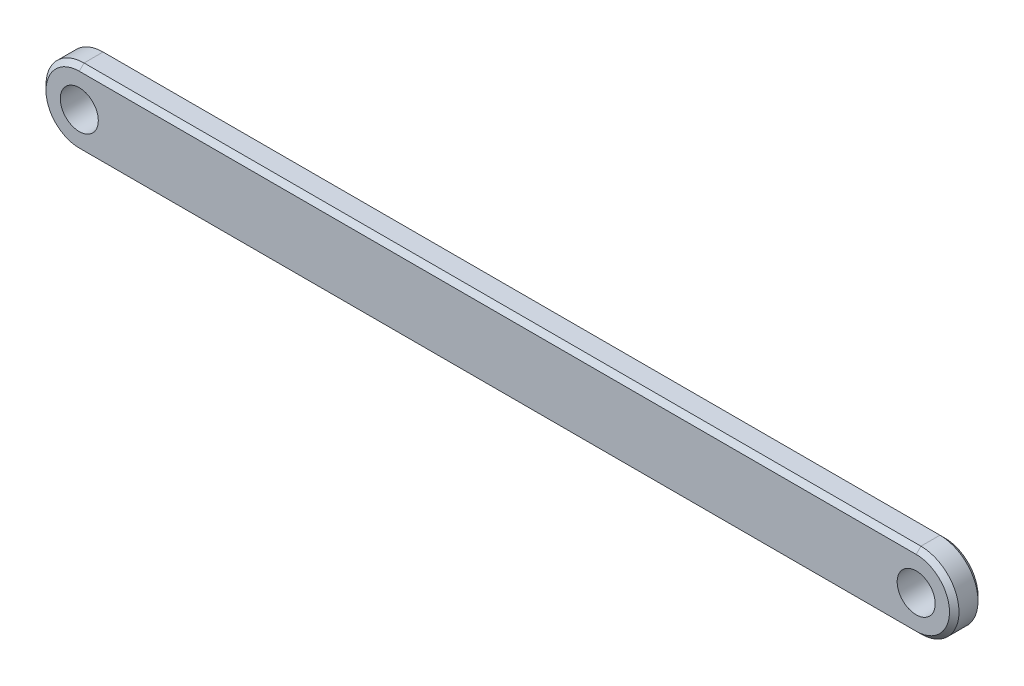
from build123d import *

# Parameters (mm, degrees)
SKETCH1_R           = 2
BOSS_EXTRUDE1_DEPTH = 3
CHAMFER1_SIZE       = 0.5


with BuildPart() as part:
    # Sketch1 → Boss-Extrude1 (new body)
    with BuildSketch(Plane.XY):
        with BuildLine():
            Line((-44, 4), (44, 4))
            ThreePointArc((44, 4), (48, 0), (44, -4))
            Line((44, -4), (-44, -4))
            ThreePointArc((-44, -4), (-48, 0), (-44, 4))
        make_face()
        with Locations((-44, 0)):
            Circle(SKETCH1_R, mode=Mode.SUBTRACT)
        with Locations((44, 0)):
            Circle(SKETCH1_R, mode=Mode.SUBTRACT)
    extrude(amount=BOSS_EXTRUDE1_DEPTH)

    # Chamfer1
    chamfer1_edges = [part.edges().sort_by_distance(p)[0] for p in [
        (48, 0, 3),
        (0, 4, 3),
        (-48, 0, 3),
        (0, 4, 0),
        (48, 0, 0),
        (0, -4, 0),
        (-48, 0, 0),
        (0, -4, 3),
    ]]
    chamfer(chamfer1_edges, length=CHAMFER1_SIZE)


solid = part.part
